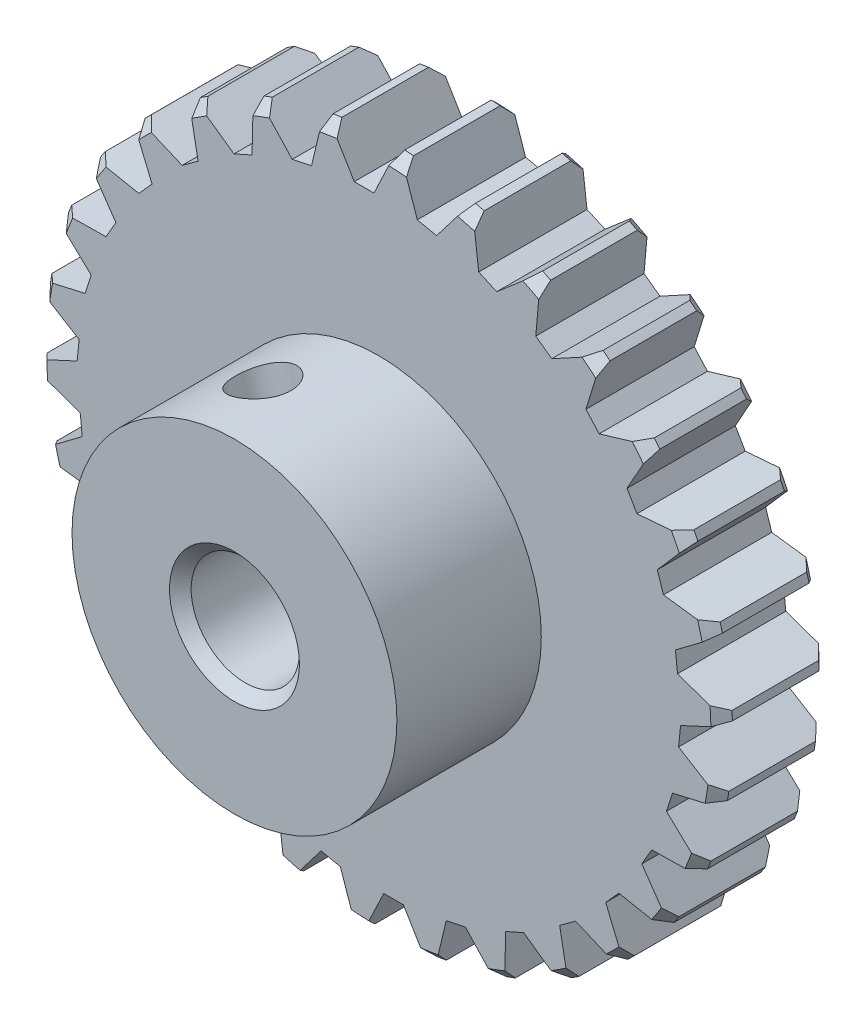
from build123d import *

# Parameters (mm, degrees)
SKETCH_1_R               = 9.5
SKETCH_1_R_2             = 1.5
EXTRUDE_1_DEPTH          = 3
SKETCH_2_R               = 4.5
SKETCH_2_R_2             = 1.5
EXTRUDE_2_DEPTH          = 4
CHAMFER_1_SIZE           = 0.3
HOLE_WIZARD_M2_1_D       = 1.6
HOLE_WIZARD_M2_1_DEPTH   = 4
HOLE_WIZARD_M2_1_TIP     = 0.480688495
CUT_EXTRUDE_1_DEPTH      = 16.149257454
PATTERN_CIRCULAR_1_COUNT = 30
CHAMFER_2_SIZE           = 0.3


with BuildPart() as part:
    # 草图1 → 凸台-拉伸1 (new body)
    with BuildSketch(Plane.XY):
        Circle(SKETCH_1_R)
        Circle(SKETCH_1_R_2, mode=Mode.SUBTRACT)
    extrude(amount=EXTRUDE_1_DEPTH)

    # 草图2 → 凸台-拉伸2 (add)
    with BuildSketch(Plane.XY.offset(3)):
        Circle(SKETCH_2_R)
        Circle(SKETCH_2_R_2, mode=Mode.SUBTRACT)
    extrude(amount=EXTRUDE_2_DEPTH)

    # 倒角1
    chamfer_1_edges = [part.edges().sort_by_distance(p)[0] for p in [
        (-9.5, 0, 0),
        (-9.5, 0, 3),
    ]]
    chamfer(chamfer_1_edges, length=CHAMFER_1_SIZE)

    # M2 螺纹孔1
    with Locations(Plane(origin=(-1.18751072, 4.340485951, 5.035709642), x_dir=(0.964552433538, 0.263891271088, 0), z_dir=(-0.263891271088, 0.964552433538, 0))):
        with Locations((0, 0)):
            Hole(HOLE_WIZARD_M2_1_D / 2, depth=HOLE_WIZARD_M2_1_DEPTH)
            with Locations((0, 0, -(HOLE_WIZARD_M2_1_DEPTH + HOLE_WIZARD_M2_1_TIP / 2))):  # 118° drill point
                Cone(0, HOLE_WIZARD_M2_1_D / 2, HOLE_WIZARD_M2_1_TIP, mode=Mode.SUBTRACT)

    # 草图4 → 切除-拉伸1 (cut, through all)
    with BuildSketch(Plane(origin=(0, 0, 0), x_dir=(-1, 0, 0), z_dir=(0, 0, -1))):
        Polygon((-0.507194631, 9.687793932), (1.492805369, 9.687793932), (0.682069756, 8.333577681), (0.135490924, 8.333577681), align=None)
    cut_extrude_1 = extrude(amount=-CUT_EXTRUDE_1_DEPTH, mode=Mode.SUBTRACT)

    # 阵列(圆周)1: 切除-拉伸1 ×30 about axis
    pattern_circular_1_axis = Axis((0, 0, 0), (0, 0, -1))
    for i in range(1, PATTERN_CIRCULAR_1_COUNT):
        add(cut_extrude_1.rotate(pattern_circular_1_axis, i * 360 / PATTERN_CIRCULAR_1_COUNT), mode=Mode.SUBTRACT)

    # 倒角2
    chamfer_2_edges = [part.edges().sort_by_distance(p)[0] for p in [
        (-1.5, 0, 7),
    ]]
    chamfer(chamfer_2_edges, length=CHAMFER_2_SIZE)


solid = part.part
